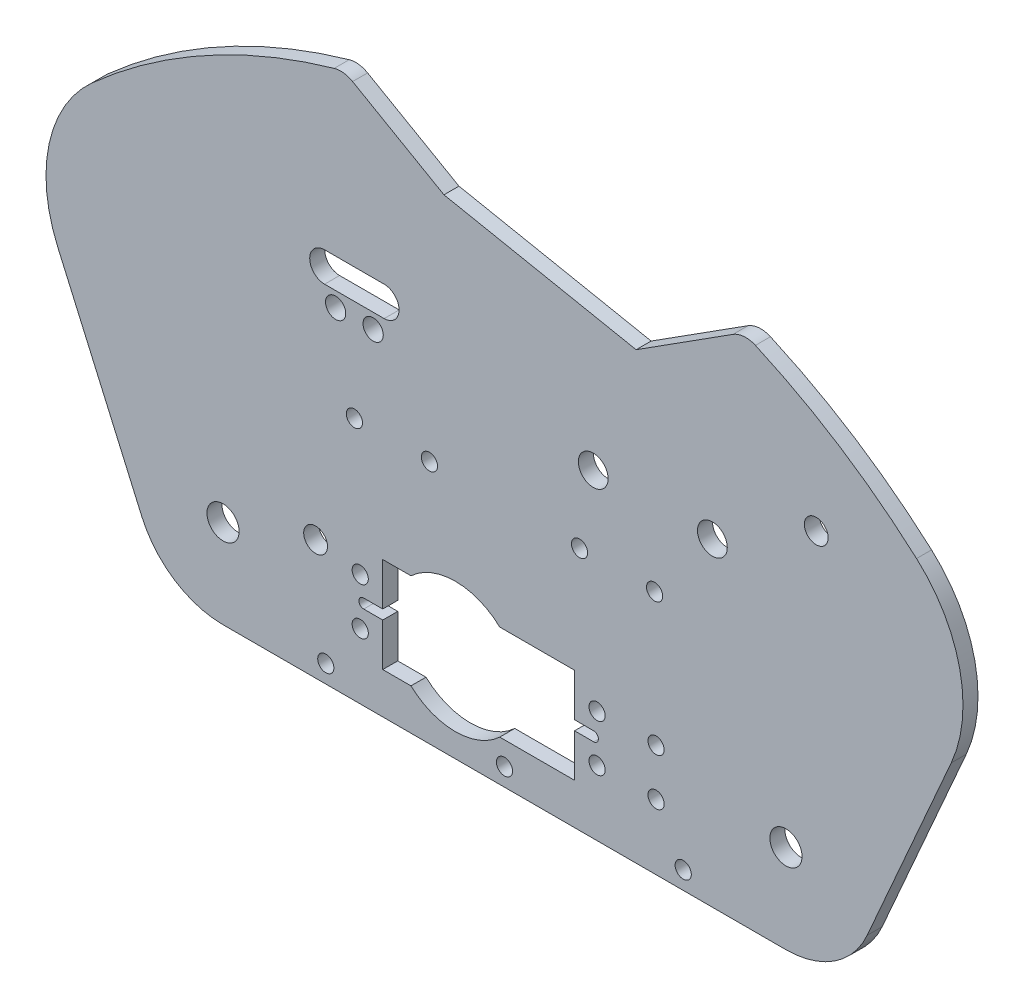
from build123d import *

# Parameters (mm, degrees)
SKETCH1_R           = 3.429
SKETCH1_R_2         = 2.54
BOSS_EXTRUDE1_DEPTH = 3.2004
SKETCH2_R           = 1.7272
CUT_EXTRUDE1_DEPTH  = 3.2004
SKETCH5_R           = 1.7272
SKETCH5_W           = 40.894
SKETCH5_H           = 20.32
CUT_EXTRUDE3_DEPTH  = 4.2004
CUT_EXTRUDE4_DEPTH  = 3.2004
SKETCH8_R           = 1.7272
CUT_EXTRUDE6_DEPTH  = 3.2004
SKETCH9_R           = 2.54
CUT_EXTRUDE7_DEPTH  = 3.2004
CUT_EXTRUDE8_DEPTH  = 3.2004
FILLET1_R           = 5.08
SKETCH12_R          = 2.159
CUT_EXTRUDE10_DEPTH = 3.2004
SKETCH13_R          = 13.885201093
CUT_EXTRUDE11_DEPTH = 3.2004
SKETCH14_R          = 3.175
CUT_EXTRUDE12_DEPTH = 3.2004


with BuildPart() as part:
    # Sketch1 → Boss-Extrude1 (new body)
    with BuildSketch(Plane.XY):
        with BuildLine():
            Line((0, 0), (120.015, 0))
            ThreePointArc((120.015, 0), (130.351788396, 3.075697789), (137.325636158, 11.302152592))
            Line((137.325636158, 11.302152592), (155.2575, 52.11572))
            ThreePointArc((155.2575, 52.11572), (157.086103359, 70.33575546), (147.862829498, 86.154880014))
            ThreePointArc((147.862829498, 86.154880014), (60.0075, 119.675648405), (-27.847829498, 86.154880014))
            ThreePointArc((-27.847829498, 86.154880014), (-37.071103359, 70.33575546), (-35.2425, 52.11572))
            Line((-35.2425, 52.11572), (-17.310636158, 11.302152592))
            ThreePointArc((-17.310636158, 11.302152592), (-10.336788396, 3.075697789), (0, 0))
        make_face()
        with Locations((120.015, 18.90776)):
            Circle(SKETCH1_R, mode=Mode.SUBTRACT)
        with Locations((0, 18.90776)):
            Circle(SKETCH1_R, mode=Mode.SUBTRACT)
        with Locations((19.734727639, 25.566426996)):
            Circle(SKETCH1_R_2, mode=Mode.SUBTRACT)
    extrude(amount=BOSS_EXTRUDE1_DEPTH)

    # Sketch2 → Cut-Extrude1 (cut)
    with BuildSketch(Plane(origin=(0, 0, 0), x_dir=(-1, 0, 0), z_dir=(0, 0, -1))):
        with Locations((-92.0115, 52.11572)):
            Circle(SKETCH2_R)
        with Locations((-76.0095, 52.11572)):
            Circle(SKETCH2_R)
        with Locations((-44.0055, 52.11572)):
            Circle(SKETCH2_R)
        with Locations((-28.0035, 52.11572)):
            Circle(SKETCH2_R)
    extrude(amount=-CUT_EXTRUDE1_DEPTH, mode=Mode.SUBTRACT)

    # Sketch5 → Cut-Extrude3 (cut, through all)
    with BuildSketch(Plane(origin=(0, 0, 0), x_dir=(-1, 0, 0), z_dir=(0, 0, -1))):
        with Locations((-79.746999972, 23.90776)):
            Circle(SKETCH5_R)
        with Locations((-29.246999972, 13.90776)):
            Circle(SKETCH5_R)
        with Locations((-29.246999972, 23.90776)):
            Circle(SKETCH5_R)
        with Locations((-79.746999972, 13.90776)):
            Circle(SKETCH5_R)
        with Locations((-92.322240346, 23.90776)):
            Circle(SKETCH5_R)
        with Locations((-92.322240346, 13.90776)):
            Circle(SKETCH5_R)
        with Locations((-54.496999972, 18.90776)):
            Rectangle(SKETCH5_W, SKETCH5_H)
    extrude(amount=-CUT_EXTRUDE3_DEPTH, mode=Mode.SUBTRACT)

    # Sketch6 → Cut-Extrude4 (cut)
    with BuildSketch(Plane.XY.offset(3.2004)):
        with BuildLine():
            Line((29.985999972, 19.92376), (34.049999972, 19.92376))
            Line((34.049999972, 19.92376), (34.049999972, 17.89176))
            Line((34.049999972, 17.89176), (29.985999972, 17.89176))
            ThreePointArc((29.985999972, 17.89176), (28.969999972, 18.90776), (29.985999972, 19.92376))
        make_face()
        with BuildLine():
            Line((74.943999972, 19.92376), (79.007999972, 19.92376))
            ThreePointArc((79.007999972, 19.92376), (80.023999972, 18.90776), (79.007999972, 17.89176))
            Line((79.007999972, 17.89176), (74.943999972, 17.89176))
            Line((74.943999972, 17.89176), (74.943999972, 19.92376))
        make_face()
    extrude(amount=-CUT_EXTRUDE4_DEPTH, mode=Mode.SUBTRACT)

    # Sketch8 → Cut-Extrude6 (cut)
    with BuildSketch(Plane.XY.offset(3.2004)):
        with Locations((21.9075, 3.81)):
            Circle(SKETCH8_R)
        with Locations((60.0075, 3.81)):
            Circle(SKETCH8_R)
        with Locations((98.1075, 3.81)):
            Circle(SKETCH8_R)
    extrude(amount=-CUT_EXTRUDE6_DEPTH, mode=Mode.SUBTRACT)

    # Sketch9 → Cut-Extrude7 (cut)
    with BuildSketch(Plane.XY.offset(3.2004)):
        with Locations((126.474462556, 80.535782848)):
            Circle(SKETCH9_R)
    extrude(amount=-CUT_EXTRUDE7_DEPTH, mode=Mode.SUBTRACT)

    # Sketch10 → Cut-Extrude8 (cut)
    with BuildSketch(Plane.XY.offset(3.2004)):
        with BuildLine():
            Line((25.781769816, 115.1574819), (47.097944047, 102.932721584))
            Line((47.097944047, 102.932721584), (88.071918158, 94.816913209))
            Line((88.071918158, 94.816913209), (110.992429932, 109.422556159))
            ThreePointArc((110.992429932, 109.422556159), (68.86413804, 119.377946373), (25.781769816, 115.1574819))
        make_face()
    extrude(amount=-CUT_EXTRUDE8_DEPTH, mode=Mode.SUBTRACT)

    # Fillet1
    fillet1_edges = [part.edges().sort_by_distance(p)[0] for p in [
        (110.992429932, 109.422556159, 1.6002),
        (25.781769816, 115.1574819, 1.6002),
    ]]
    fillet(fillet1_edges, radius=FILLET1_R)

    # Sketch12 → Cut-Extrude10 (cut)
    with BuildSketch(Plane.XY.offset(3.2004)):
        with Locations((24.003, 70.53072)):
            Circle(SKETCH12_R)
        with Locations((32.004, 70.53072)):
            Circle(SKETCH12_R)
        with BuildLine():
            Line((21.6535, 80.05572), (34.3535, 80.05572))
            ThreePointArc((34.3535, 80.05572), (37.5285, 76.88072), (34.3535, 73.70572))
            Line((34.3535, 73.70572), (21.6535, 73.70572))
            ThreePointArc((21.6535, 73.70572), (18.4785, 76.88072), (21.6535, 80.05572))
        make_face()
    extrude(amount=-CUT_EXTRUDE10_DEPTH, mode=Mode.SUBTRACT)

    # Sketch13 → Cut-Extrude11 (cut)
    with BuildSketch(Plane.XY.offset(3.2004)):
        with Locations((49.53, 18.90776)):
            Circle(SKETCH13_R)
    extrude(amount=-CUT_EXTRUDE11_DEPTH, mode=Mode.SUBTRACT)

    # Sketch14 → Cut-Extrude12 (cut)
    with BuildSketch(Plane.XY.offset(3.2004)):
        with Locations((78.9305, 67.99072)):
            Circle(SKETCH14_R)
        with Locations((104.3305, 67.99072)):
            Circle(SKETCH14_R)
    extrude(amount=-CUT_EXTRUDE12_DEPTH, mode=Mode.SUBTRACT)


solid = part.part
